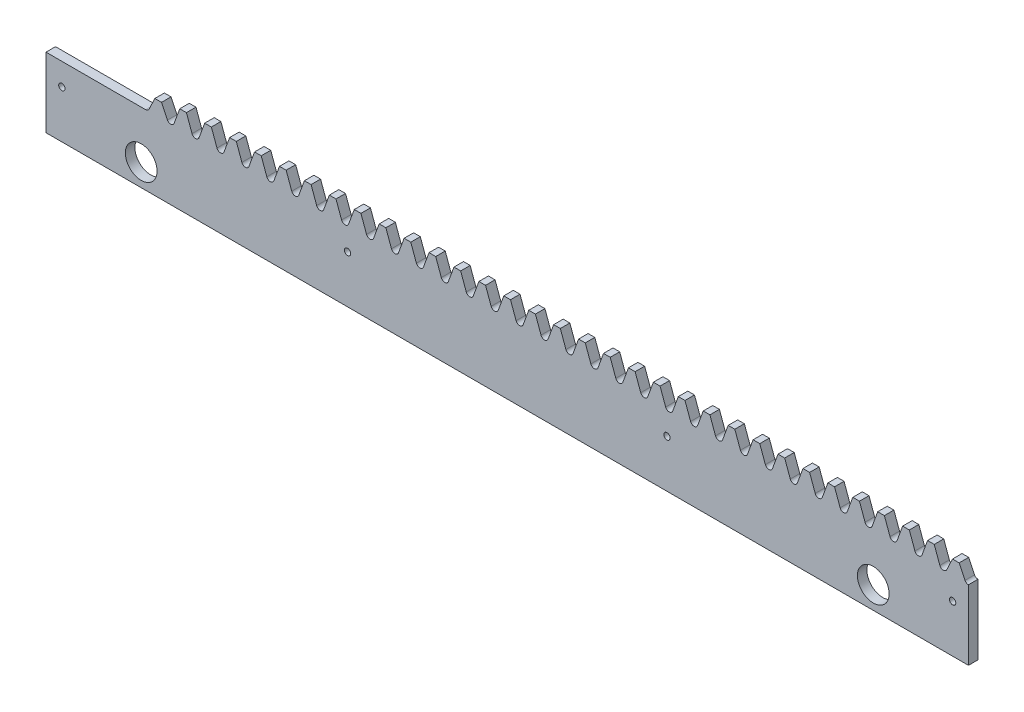
from build123d import *

# Parameters (mm, degrees)
ESQUISSE1_R             = 1
EXTRUSION1_DEPTH        = 3
ESQUISSE4_R             = 5
ENL_V_MAT_EXTRU_2_DEPTH = 4


with BuildPart() as part:
    # Esquisse1 → Extrusion1 (new body)
    with BuildSketch(Plane.XY):
        with BuildLine():
            Line((-11.780972452, 22), (19.634954087, 22))
            ThreePointArc((19.634954087, 22), (20.207764851, 22.148388876), (20.636482657, 22.556227657))
            Line((20.636482657, 22.556227657), (22.508375082, 26.5))
            Line((22.508375082, 26.5), (24.615514728, 26.5))
            Line((24.615514728, 26.5), (26.487407153, 22.556227657))
            ThreePointArc((26.487407153, 22.556227657), (26.916124959, 22.148388876), (27.488935722, 22))
            ThreePointArc((27.488935722, 22), (28.165627746, 22.213360175), (28.597563031, 22.776269199))
            Line((28.597563031, 22.776269199), (30.362356717, 27.625))
            Line((30.362356717, 27.625), (32.469496363, 27.625))
            Line((32.469496363, 27.625), (34.234290049, 22.776269199))
            ThreePointArc((34.234290049, 22.776269199), (34.666225334, 22.213360175), (35.342917357, 22))
            ThreePointArc((35.342917357, 22), (36.019609381, 22.213360175), (36.451544666, 22.776269199))
            Line((36.451544666, 22.776269199), (38.216338352, 27.625))
            Line((38.216338352, 27.625), (40.323477998, 27.625))
            Line((40.323477998, 27.625), (42.088271684, 22.776269199))
            ThreePointArc((42.088271684, 22.776269199), (42.520206969, 22.213360175), (43.196898992, 22))
            ThreePointArc((43.196898992, 22), (43.873591016, 22.213360175), (44.305526301, 22.776269199))
            Line((44.305526301, 22.776269199), (46.070319987, 27.625))
            Line((46.070319987, 27.625), (48.177459633, 27.625))
            Line((48.177459633, 27.625), (49.942253319, 22.776269199))
            ThreePointArc((49.942253319, 22.776269199), (50.374188604, 22.213360175), (51.050880627, 22))
            ThreePointArc((51.050880627, 22), (51.727572651, 22.213360175), (52.159507936, 22.776269199))
            Line((52.159507936, 22.776269199), (53.924301622, 27.625))
            Line((53.924301622, 27.625), (56.031441268, 27.625))
            Line((56.031441268, 27.625), (57.796234954, 22.776269199))
            ThreePointArc((57.796234954, 22.776269199), (58.228170239, 22.213360175), (58.904862262, 22))
            ThreePointArc((58.904862262, 22), (59.581554286, 22.213360175), (60.013489571, 22.776269199))
            Line((60.013489571, 22.776269199), (61.778283257, 27.625))
            Line((61.778283257, 27.625), (63.885422903, 27.625))
            Line((63.885422903, 27.625), (65.650216589, 22.776269199))
            ThreePointArc((65.650216589, 22.776269199), (66.082151874, 22.213360175), (66.758843897, 22))
            ThreePointArc((66.758843897, 22), (67.435535921, 22.213360175), (67.867471206, 22.776269199))
            Line((67.867471206, 22.776269199), (69.632264892, 27.625))
            Line((69.632264892, 27.625), (71.739404538, 27.625))
            Line((71.739404538, 27.625), (73.504198224, 22.776269199))
            ThreePointArc((73.504198224, 22.776269199), (73.936133509, 22.213360175), (74.612825532, 22))
            ThreePointArc((74.612825532, 22), (75.289517556, 22.213360175), (75.721452841, 22.776269199))
            Line((75.721452841, 22.776269199), (77.486246527, 27.625))
            Line((77.486246527, 27.625), (79.593386173, 27.625))
            Line((79.593386173, 27.625), (81.358179859, 22.776269199))
            ThreePointArc((81.358179859, 22.776269199), (81.790115144, 22.213360175), (82.466807167, 22))
            ThreePointArc((82.466807167, 22), (83.143499191, 22.213360175), (83.575434476, 22.776269199))
            Line((83.575434476, 22.776269199), (85.340228162, 27.625))
            Line((85.340228162, 27.625), (87.447367808, 27.625))
            Line((87.447367808, 27.625), (89.212161494, 22.776269199))
            ThreePointArc((89.212161494, 22.776269199), (89.644096779, 22.213360175), (90.320788802, 22))
            ThreePointArc((90.320788802, 22), (90.997480826, 22.213360175), (91.429416111, 22.776269199))
            Line((91.429416111, 22.776269199), (93.194209797, 27.625))
            Line((93.194209797, 27.625), (95.301349443, 27.625))
            Line((95.301349443, 27.625), (97.066143129, 22.776269199))
            ThreePointArc((97.066143129, 22.776269199), (97.498078414, 22.213360175), (98.174770437, 22))
            ThreePointArc((98.174770437, 22), (98.851462461, 22.213360175), (99.283397746, 22.776269199))
            Line((99.283397746, 22.776269199), (101.048191432, 27.625))
            Line((101.048191432, 27.625), (103.155331078, 27.625))
            Line((103.155331078, 27.625), (104.920124764, 22.776269199))
            ThreePointArc((104.920124764, 22.776269199), (105.352060049, 22.213360175), (106.028752072, 22))
            ThreePointArc((106.028752072, 22), (106.705444096, 22.213360175), (107.137379381, 22.776269199))
            Line((107.137379381, 22.776269199), (108.902173067, 27.625))
            Line((108.902173067, 27.625), (111.009312713, 27.625))
            Line((111.009312713, 27.625), (112.774106399, 22.776269199))
            ThreePointArc((112.774106399, 22.776269199), (113.206041684, 22.213360175), (113.882733707, 22))
            ThreePointArc((113.882733707, 22), (114.559425731, 22.213360175), (114.991361016, 22.776269199))
            Line((114.991361016, 22.776269199), (116.756154702, 27.625))
            Line((116.756154702, 27.625), (118.863294348, 27.625))
            Line((118.863294348, 27.625), (120.628088034, 22.776269199))
            ThreePointArc((120.628088034, 22.776269199), (121.060023319, 22.213360175), (121.736715342, 22))
            ThreePointArc((121.736715342, 22), (122.413407366, 22.213360175), (122.845342651, 22.776269199))
            Line((122.845342651, 22.776269199), (124.610136337, 27.625))
            Line((124.610136337, 27.625), (126.717275983, 27.625))
            Line((126.717275983, 27.625), (128.482069669, 22.776269199))
            ThreePointArc((128.482069669, 22.776269199), (128.914004954, 22.213360175), (129.590696977, 22))
            ThreePointArc((129.590696977, 22), (130.267389001, 22.213360175), (130.699324286, 22.776269199))
            Line((130.699324286, 22.776269199), (132.464117972, 27.625))
            Line((132.464117972, 27.625), (134.571257618, 27.625))
            Line((134.571257618, 27.625), (136.336051304, 22.776269199))
            ThreePointArc((136.336051304, 22.776269199), (136.767986589, 22.213360175), (137.444678612, 22))
            ThreePointArc((137.444678612, 22), (138.121370636, 22.213360175), (138.553305921, 22.776269199))
            Line((138.553305921, 22.776269199), (140.318099607, 27.625))
            Line((140.318099607, 27.625), (142.425239253, 27.625))
            Line((142.425239253, 27.625), (144.190032939, 22.776269199))
            ThreePointArc((144.190032939, 22.776269199), (144.621968224, 22.213360175), (145.298660247, 22))
            ThreePointArc((145.298660247, 22), (145.975352271, 22.213360175), (146.407287556, 22.776269199))
            Line((146.407287556, 22.776269199), (148.172081242, 27.625))
            Line((148.172081242, 27.625), (150.279220888, 27.625))
            Line((150.279220888, 27.625), (152.044014574, 22.776269199))
            ThreePointArc((152.044014574, 22.776269199), (152.475949859, 22.213360175), (153.152641882, 22))
            ThreePointArc((153.152641882, 22), (153.829333906, 22.213360175), (154.261269191, 22.776269199))
            Line((154.261269191, 22.776269199), (156.026062877, 27.625))
            Line((156.026062877, 27.625), (158.133202523, 27.625))
            Line((158.133202523, 27.625), (159.897996209, 22.776269199))
            ThreePointArc((159.897996209, 22.776269199), (160.329931494, 22.213360175), (161.006623517, 22))
            ThreePointArc((161.006623517, 22), (161.683315541, 22.213360175), (162.115250826, 22.776269199))
            Line((162.115250826, 22.776269199), (163.880044512, 27.625))
            Line((163.880044512, 27.625), (165.987184158, 27.625))
            Line((165.987184158, 27.625), (167.751977844, 22.776269199))
            ThreePointArc((167.751977844, 22.776269199), (168.183913129, 22.213360175), (168.860605152, 22))
            ThreePointArc((168.860605152, 22), (169.537297176, 22.213360175), (169.969232461, 22.776269199))
            Line((169.969232461, 22.776269199), (171.734026147, 27.625))
            Line((171.734026147, 27.625), (173.841165793, 27.625))
            Line((173.841165793, 27.625), (175.605959479, 22.776269199))
            ThreePointArc((175.605959479, 22.776269199), (176.037894764, 22.213360175), (176.714586787, 22))
            ThreePointArc((176.714586787, 22), (177.391278811, 22.213360175), (177.823214096, 22.776269199))
            Line((177.823214096, 22.776269199), (179.588007782, 27.625))
            Line((179.588007782, 27.625), (181.695147428, 27.625))
            Line((181.695147428, 27.625), (183.459941114, 22.776269199))
            ThreePointArc((183.459941114, 22.776269199), (183.891876399, 22.213360175), (184.568568422, 22))
            ThreePointArc((184.568568422, 22), (185.245260446, 22.213360175), (185.677195731, 22.776269199))
            Line((185.677195731, 22.776269199), (187.441989417, 27.625))
            Line((187.441989417, 27.625), (189.549129063, 27.625))
            Line((189.549129063, 27.625), (191.313922749, 22.776269199))
            ThreePointArc((191.313922749, 22.776269199), (191.745858034, 22.213360175), (192.422550057, 22))
            ThreePointArc((192.422550057, 22), (193.099242081, 22.213360175), (193.531177366, 22.776269199))
            Line((193.531177366, 22.776269199), (195.295971052, 27.625))
            Line((195.295971052, 27.625), (197.403110698, 27.625))
            Line((197.403110698, 27.625), (199.167904384, 22.776269199))
            ThreePointArc((199.167904384, 22.776269199), (199.599839669, 22.213360175), (200.276531692, 22))
            ThreePointArc((200.276531692, 22), (200.953223716, 22.213360175), (201.385159001, 22.776269199))
            Line((201.385159001, 22.776269199), (203.149952687, 27.625))
            Line((203.149952687, 27.625), (205.257092333, 27.625))
            Line((205.257092333, 27.625), (207.021886019, 22.776269199))
            ThreePointArc((207.021886019, 22.776269199), (207.453821304, 22.213360175), (208.130513327, 22))
            ThreePointArc((208.130513327, 22), (208.807205351, 22.213360175), (209.239140636, 22.776269199))
            Line((209.239140636, 22.776269199), (211.003934322, 27.625))
            Line((211.003934322, 27.625), (213.111073968, 27.625))
            Line((213.111073968, 27.625), (214.875867654, 22.776269199))
            ThreePointArc((214.875867654, 22.776269199), (215.307802939, 22.213360175), (215.984494962, 22))
            ThreePointArc((215.984494962, 22), (216.661186986, 22.213360175), (217.093122271, 22.776269199))
            Line((217.093122271, 22.776269199), (218.857915957, 27.625))
            Line((218.857915957, 27.625), (220.965055603, 27.625))
            Line((220.965055603, 27.625), (222.729849289, 22.776269199))
            ThreePointArc((222.729849289, 22.776269199), (223.161784574, 22.213360175), (223.838476597, 22))
            ThreePointArc((223.838476597, 22), (224.515168621, 22.213360175), (224.947103906, 22.776269199))
            Line((224.947103906, 22.776269199), (226.711897592, 27.625))
            Line((226.711897592, 27.625), (228.819037238, 27.625))
            Line((228.819037238, 27.625), (230.583830924, 22.776269199))
            ThreePointArc((230.583830924, 22.776269199), (231.015766209, 22.213360175), (231.692458232, 22))
            ThreePointArc((231.692458232, 22), (232.369150256, 22.213360175), (232.801085541, 22.776269199))
            Line((232.801085541, 22.776269199), (234.565879227, 27.625))
            Line((234.565879227, 27.625), (236.673018873, 27.625))
            Line((236.673018873, 27.625), (238.437812559, 22.776269199))
            ThreePointArc((238.437812559, 22.776269199), (238.869747844, 22.213360175), (239.546439867, 22))
            ThreePointArc((239.546439867, 22), (240.223131891, 22.213360175), (240.655067176, 22.776269199))
            Line((240.655067176, 22.776269199), (242.419860862, 27.625))
            Line((242.419860862, 27.625), (244.527000508, 27.625))
            Line((244.527000508, 27.625), (246.291794194, 22.776269199))
            ThreePointArc((246.291794194, 22.776269199), (246.723729479, 22.213360175), (247.400421502, 22))
            ThreePointArc((247.400421502, 22), (248.077113526, 22.213360175), (248.509048811, 22.776269199))
            Line((248.509048811, 22.776269199), (250.273842497, 27.625))
            Line((250.273842497, 27.625), (252.380982143, 27.625))
            Line((252.380982143, 27.625), (254.145775829, 22.776269199))
            ThreePointArc((254.145775829, 22.776269199), (254.577711114, 22.213360175), (255.254403137, 22))
            ThreePointArc((255.254403137, 22), (255.931095161, 22.213360175), (256.363030446, 22.776269199))
            Line((256.363030446, 22.776269199), (258.127824132, 27.625))
            Line((258.127824132, 27.625), (260.234963778, 27.625))
            Line((260.234963778, 27.625), (261.999757464, 22.776269199))
            ThreePointArc((261.999757464, 22.776269199), (262.431692749, 22.213360175), (263.108384772, 22))
            ThreePointArc((263.108384772, 22), (263.785076796, 22.213360175), (264.217012081, 22.776269199))
            Line((264.217012081, 22.776269199), (265.981805767, 27.625))
            Line((265.981805767, 27.625), (268.088945413, 27.625))
            Line((268.088945413, 27.625), (269.853739099, 22.776269199))
            ThreePointArc((269.853739099, 22.776269199), (270.285674384, 22.213360175), (270.962366407, 22))
            ThreePointArc((270.962366407, 22), (271.572652612, 22.17011153), (272.006944946, 22.631389486))
            Line((272.006944946, 22.631389486), (273.835787402, 26.5))
            Line((273.835787402, 26.5), (275.942927048, 26.5))
            Line((275.942927048, 26.5), (277.771769504, 22.631389486))
            ThreePointArc((277.771769504, 22.631389486), (278.231733017, 22.155033667), (278.875867654, 22.001502336))
            Line((278.875867654, 22.001502336), (278.875867654, 0))
            Line((278.875867654, 0), (-11.780972452, 0))
            Line((-11.780972452, 0), (-11.780972452, 22))
        make_face()
        with Locations((183.875867654, 15)):
            Circle(ESQUISSE1_R, mode=Mode.SUBTRACT)
        with Locations((83.219027548, 15)):
            Circle(ESQUISSE1_R, mode=Mode.SUBTRACT)
        with Locations((-6.780972452, 15)):
            Circle(ESQUISSE1_R, mode=Mode.SUBTRACT)
        with Locations((273.875867654, 15)):
            Circle(ESQUISSE1_R, mode=Mode.SUBTRACT)
    extrude(amount=EXTRUSION1_DEPTH)

    # Esquisse4 → Enlèv. mat.-Extru.2 (cut, through all)
    with BuildSketch(Plane.XY.offset(3)):
        with Locations((18.219027547, 7)):
            Circle(ESQUISSE4_R)
        with Locations((248.875867654, 7)):
            Circle(ESQUISSE4_R)
    extrude(amount=-ENL_V_MAT_EXTRU_2_DEPTH, mode=Mode.SUBTRACT)


solid = part.part
